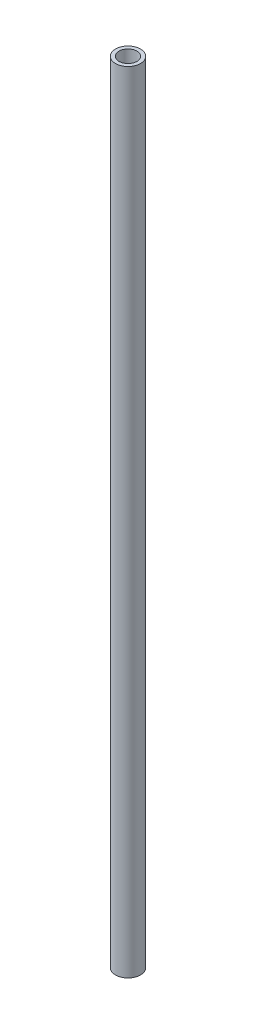
from build123d import *

# Parameters (mm, degrees)
SKETCH1_R           = 3.5
SKETCH1_R_2         = 2.5
BOSS_EXTRUDE1_DEPTH = 110


with BuildPart() as part:
    # Sketch1 → Boss-Extrude1 (new body, symmetric)
    with BuildSketch(Plane(origin=(0, 0, 0), x_dir=(1, 0, 0), z_dir=(0, 1, 0))):
        Circle(SKETCH1_R)
        Circle(SKETCH1_R_2, mode=Mode.SUBTRACT)
    extrude(amount=BOSS_EXTRUDE1_DEPTH, both=True)


solid = part.part
